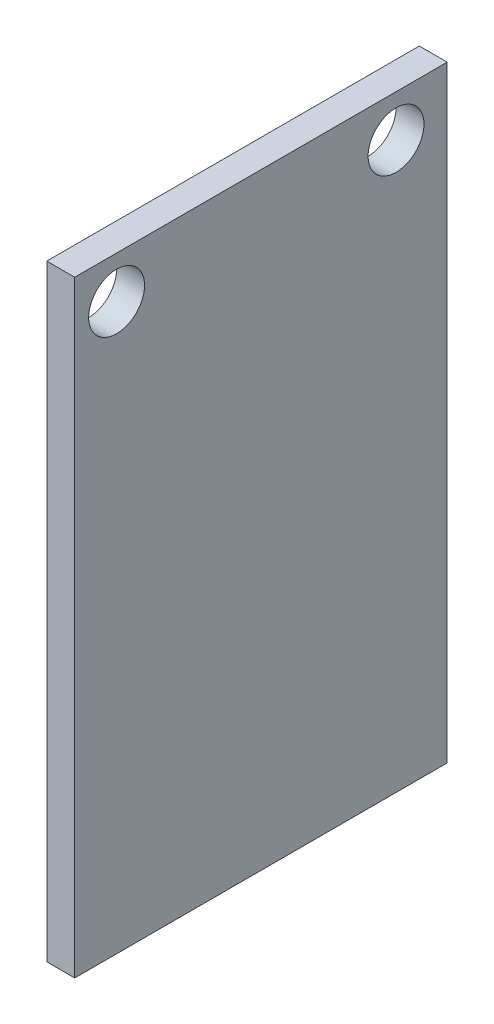
from build123d import *

# Parameters (mm, degrees)
SKETCH1_W           = 20
SKETCH1_H           = 32.58
SKETCH1_R           = 1.5
BOSS_EXTRUDE1_DEPTH = 1.5


with BuildPart() as part:
    # Sketch1 → Boss-Extrude1 (new body)
    with BuildSketch(Plane(origin=(0, 0, 0), x_dir=(0, 0, -1), z_dir=(1, 0, 0))):
        with Locations((10, -16.29)):
            Rectangle(SKETCH1_W, SKETCH1_H)
        with Locations((2.25, -2.25)):
            Circle(SKETCH1_R, mode=Mode.SUBTRACT)
        with Locations((17.25, -2.25)):
            Circle(SKETCH1_R, mode=Mode.SUBTRACT)
    extrude(amount=BOSS_EXTRUDE1_DEPTH)


solid = part.part
